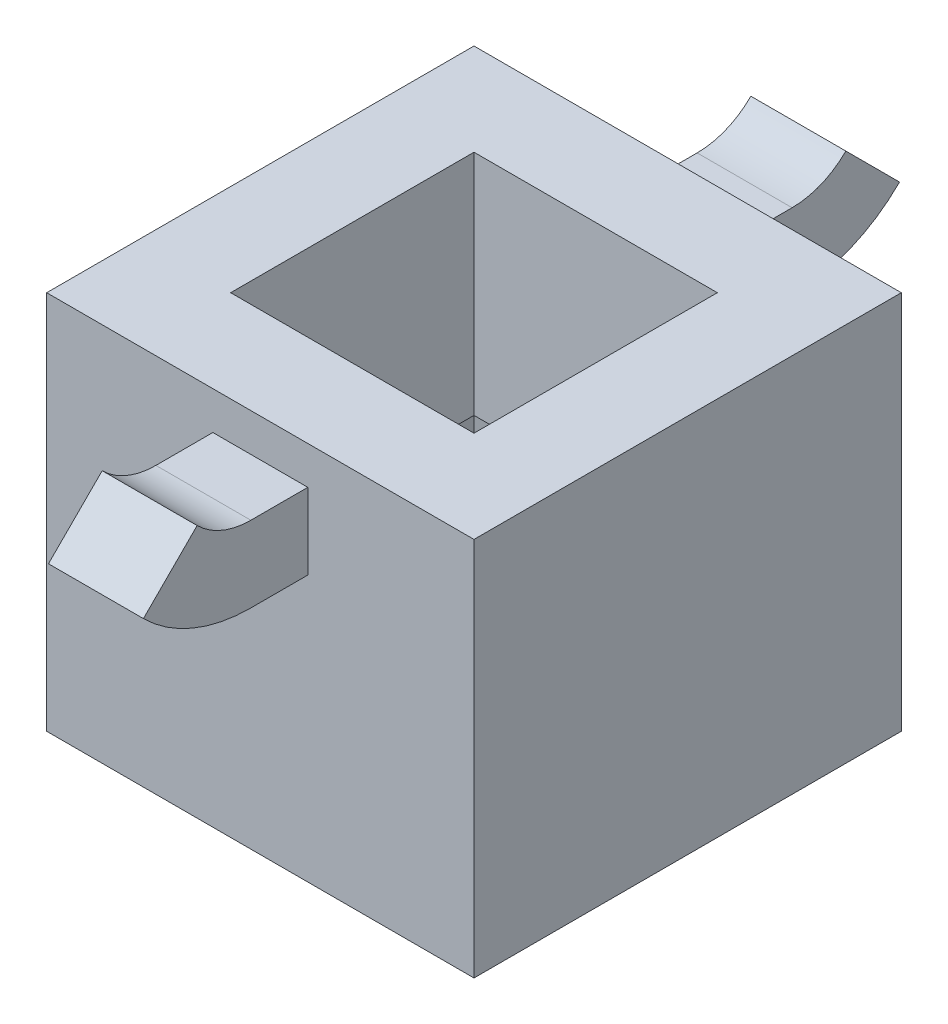
from build123d import *

# Parameters (mm, degrees)
SKETCH1_W           = 22.5
SKETCH1_H           = 22.5
BOSS_EXTRUDE1_DEPTH = 20
SKETCH5_W           = 5
SKETCH5_H           = 4
SKETCH3_W           = 18.5
SKETCH3_H           = 18.5
CUT_EXTRUDE5_DEPTH  = 6
CUT_EXTRUDE5_TAPER  = 8
SKETCH14_W          = 16.813509984
SKETCH14_H          = 16.813509984
CUT_EXTRUDE6_DEPTH  = 2
CUT_EXTRUDE7_REACH  = 14
SKETCH15_W          = 12.813509984
SKETCH15_H          = 12.813509984


with BuildPart() as part:
    # Sketch1 → Boss-Extrude1 (new body)
    with BuildSketch(Plane(origin=(0, 0, 0), x_dir=(1, 0, 0), z_dir=(0, 1, 0))):
        Rectangle(SKETCH1_W, SKETCH1_H)
    extrude(amount=BOSS_EXTRUDE1_DEPTH)

    # Sweep1: sweep along a path in Sketch6
    with BuildLine(Plane(origin=(0, 0, 0), x_dir=(0, 0, -1), z_dir=(1, 0, 0))) as sweep1_path:
        Line((11.25, 16), (14.25, 16))
        ThreePointArc((14.25, 16), (16.546100594, 16.456722805), (18.492640687, 17.757359313))
    # Sketch5 → Sweep1 (sweep)
    with BuildSketch(Plane(origin=(0, 0, -11.25), x_dir=(-1, 0, 0), z_dir=(0, 0, -1))):
        with Locations((0, 16)):
            Rectangle(SKETCH5_W, SKETCH5_H)
    sweep1 = sweep(path=sweep1_path.line)

    # Mirror1: Sweep1 across plane
    add(sweep1.mirror(Plane.XY))

    # Sketch3 → Cut-Extrude5 (cut)
    with BuildSketch(Plane.XZ):
        Rectangle(SKETCH3_W, SKETCH3_H)
    extrude(amount=-CUT_EXTRUDE5_DEPTH, taper=CUT_EXTRUDE5_TAPER, mode=Mode.SUBTRACT)

    # Sketch14 → Cut-Extrude6 (cut)
    with BuildSketch(Plane.XZ.offset(-6)):
        Rectangle(SKETCH14_W, SKETCH14_H)
    extrude(amount=-CUT_EXTRUDE6_DEPTH, mode=Mode.SUBTRACT)

    # Sketch15 → Cut-Extrude7 (cut, up to next)
    with BuildSketch(Plane.XZ.offset(-8), mode=Mode.PRIVATE) as cut_extrude7_sk1:
        Rectangle(SKETCH15_W, SKETCH15_H)
    cut_extrude7_tool1 = extrude(cut_extrude7_sk1.sketch, amount=-CUT_EXTRUDE7_REACH, mode=Mode.PRIVATE) & part.part
    add(cut_extrude7_tool1.solids().sort_by_distance((0, 8, 0))[0], mode=Mode.SUBTRACT)


solid = part.part
